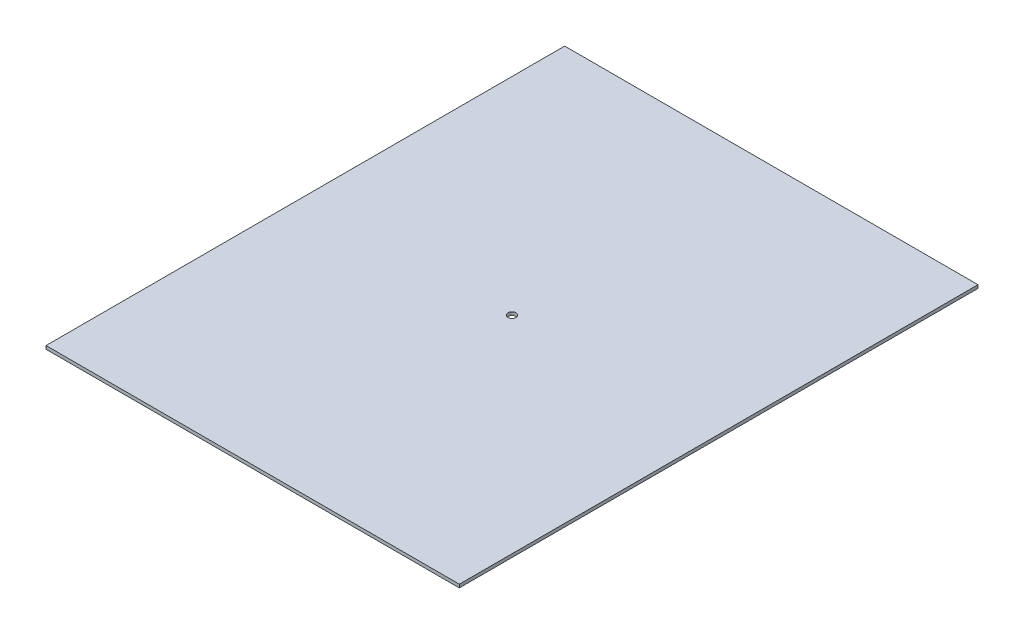
from build123d import *

# Parameters (mm, degrees)
SKETCH1_W           = 255
SKETCH1_H           = 320
SKETCH1_R           = 2.5
BOSS_EXTRUDE1_DEPTH = 2


with BuildPart() as part:
    # Sketch1 → Boss-Extrude1 (new body)
    with BuildSketch(Plane(origin=(0, 0, 0), x_dir=(1, 0, 0), z_dir=(0, 1, 0))):
        with Locations((40.369268573, 15.234375)):
            Rectangle(SKETCH1_W, SKETCH1_H)
        with Locations((40.369268573, 15.234375)):
            Circle(SKETCH1_R, mode=Mode.SUBTRACT)
    extrude(amount=BOSS_EXTRUDE1_DEPTH)


solid = part.part
